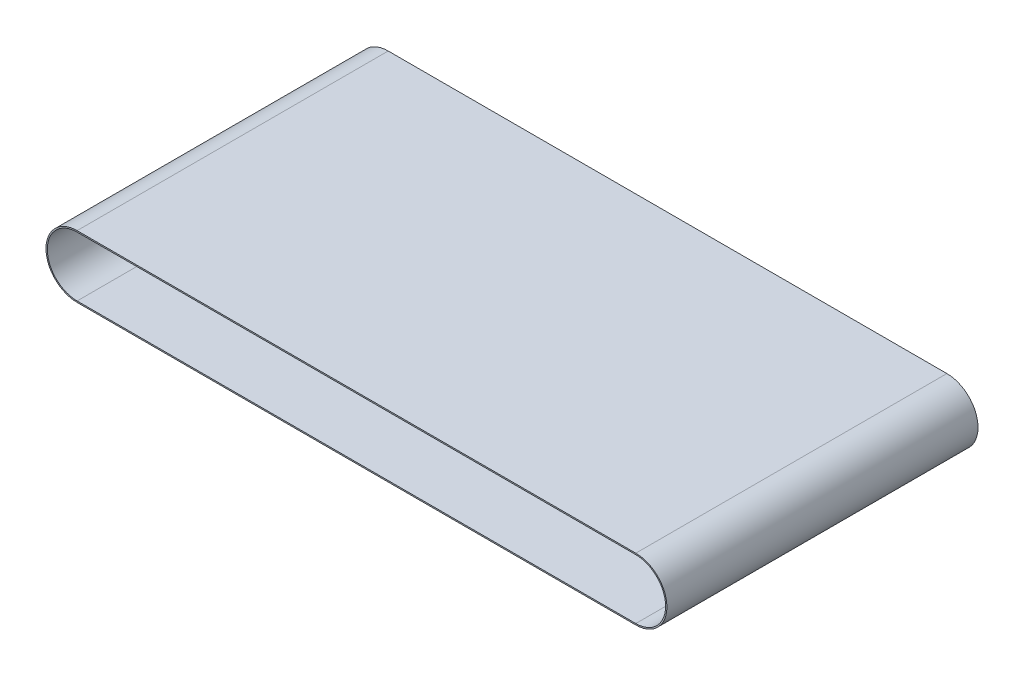
from build123d import *

# Parameters (mm, degrees)
BOSS_EXTRUDE1_DEPTH = 120


with BuildPart() as part:
    # Sketch3 → Boss-Extrude1 (new body)
    with BuildSketch(Plane.XY.offset(60)):
        with BuildLine():
            Line((-2.75, 12), (212.75, 12))
            ThreePointArc((212.75, 12), (224.75, 0), (212.75, -12))
            Line((212.75, -12), (-2.75, -12))
            ThreePointArc((-2.75, -12), (-14.75, 0), (-2.75, 12))
        make_face()
        with BuildLine():
            Line((-2.75, 11.5), (212.75, 11.5))
            ThreePointArc((212.75, 11.5), (224.25, 0), (212.75, -11.5))
            Line((212.75, -11.5), (-2.75, -11.5))
            ThreePointArc((-2.75, -11.5), (-14.25, 0), (-2.75, 11.5))
        make_face(mode=Mode.SUBTRACT)
    extrude(amount=-BOSS_EXTRUDE1_DEPTH)


solid = part.part
